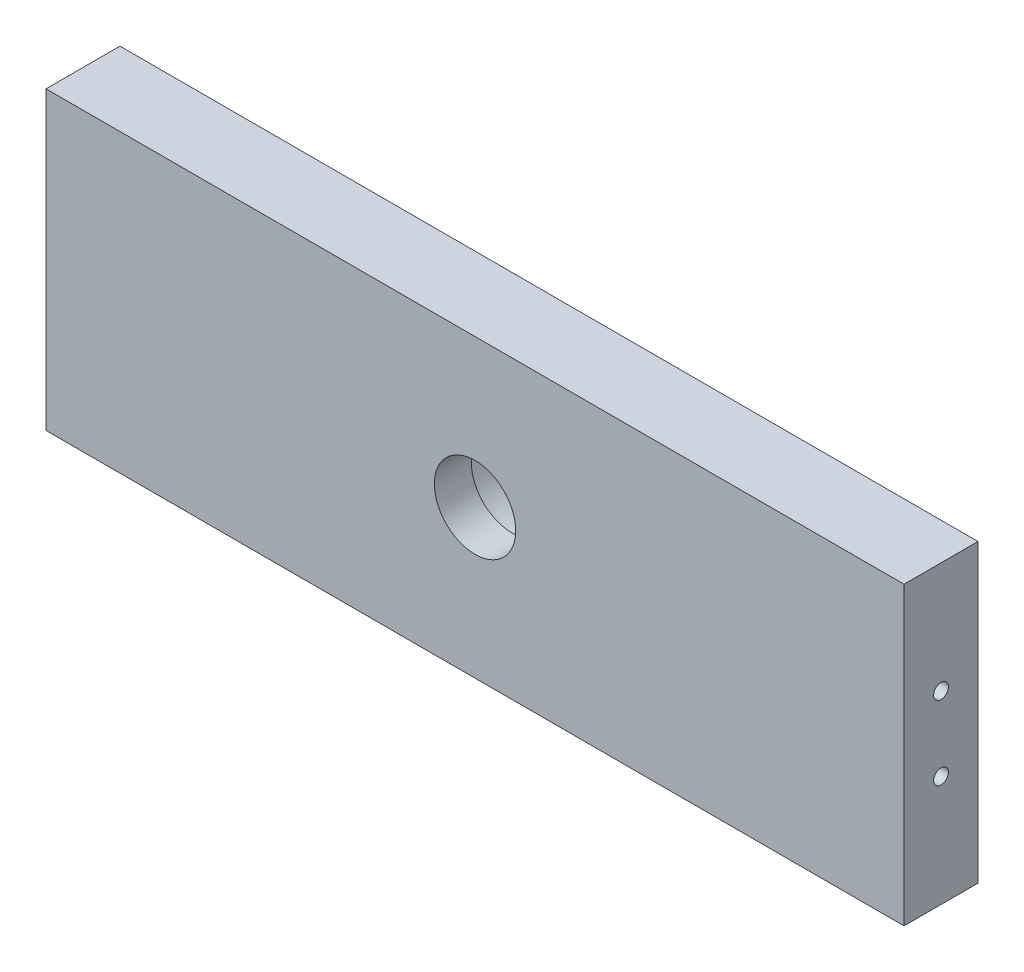
from build123d import *

# Parameters (mm, degrees)
SKETCH1_W           = 116
SKETCH1_H           = 40
SKETCH1_R           = 5.5
BOSS_EXTRUDE2_DEPTH = 10
SKETCH4_R           = 1
CUT_EXTRUDE1_DEPTH  = 10
SKETCH6_R           = 1
CUT_EXTRUDE3_DEPTH  = 10
SKETCH8_R           = 8.05
CUT_EXTRUDE8_DEPTH  = 5


with BuildPart() as part:
    # Sketch1 → Boss-Extrude2 (new body)
    with BuildSketch(Plane.XY):
        Rectangle(SKETCH1_W, SKETCH1_H)
        Circle(SKETCH1_R, mode=Mode.SUBTRACT)
    extrude(amount=BOSS_EXTRUDE2_DEPTH)

    # Sketch4 → Cut-Extrude1 (cut)
    with BuildSketch(Plane(origin=(58, 0, 0), x_dir=(0, 0, -1), z_dir=(1, 0, 0))):
        with Locations((-5, -5)):
            Circle(SKETCH4_R)
        with Locations((-5, 5)):
            Circle(SKETCH4_R)
    extrude(amount=-CUT_EXTRUDE1_DEPTH, mode=Mode.SUBTRACT)

    # Sketch6 → Cut-Extrude3 (cut)
    with BuildSketch(Plane.ZY.offset(58)):
        with Locations((5, 5)):
            Circle(SKETCH6_R)
        with Locations((5, -5)):
            Circle(SKETCH6_R)
    extrude(amount=-CUT_EXTRUDE3_DEPTH, mode=Mode.SUBTRACT)

    # Sketch8 → Cut-Extrude8 (cut)
    with BuildSketch(Plane.XY):
        Circle(SKETCH8_R)
    extrude(amount=CUT_EXTRUDE8_DEPTH, mode=Mode.SUBTRACT)


solid = part.part
